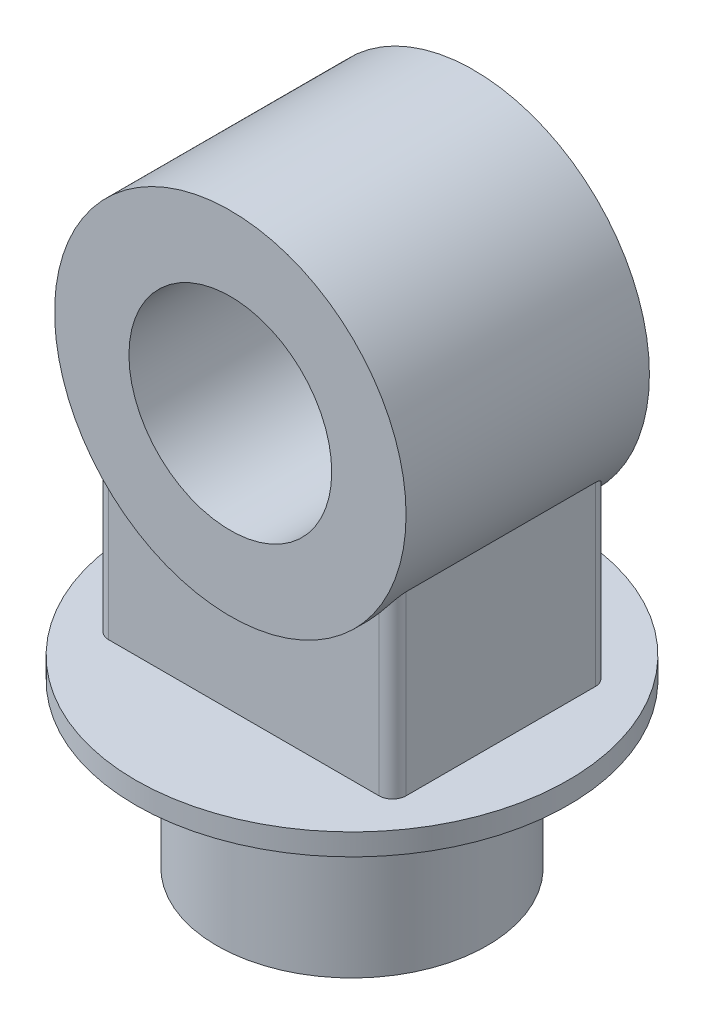
from build123d import *

# Parameters (mm, degrees)
SKETCH1_R           = 100
BOSS_EXTRUDE1_DEPTH = 120
SKETCH2_R           = 160
BOSS_EXTRUDE2_DEPTH = 16
SKETCH3_R           = 130
SKETCH3_R_2         = 75
BOSS_EXTRUDE3_DEPTH = 90
BOSS_EXTRUDE5_REACH = 402.125
SKETCH4_W           = 220
SKETCH4_H           = 160
FILLET1_R           = 10


with BuildPart() as part:
    # Sketch1 → Boss-Extrude1 (new body)
    with BuildSketch(Plane(origin=(0, 0, 0), x_dir=(1, 0, 0), z_dir=(0, 1, 0))):
        Circle(SKETCH1_R)
    extrude(amount=BOSS_EXTRUDE1_DEPTH)

    # Sketch2 → Boss-Extrude2 (add)
    with BuildSketch(Plane(origin=(0, 120, 0), x_dir=(1, 0, 0), z_dir=(0, 1, 0))):
        Circle(SKETCH2_R)
    extrude(amount=BOSS_EXTRUDE2_DEPTH)


with BuildPart() as body_2:
    # Sketch3 → Boss-Extrude3 (new, symmetric)
    with BuildSketch(Plane.XY):
        with Locations((0, 336)):
            Circle(SKETCH3_R)
        with Locations((0, 336)):
            Circle(SKETCH3_R_2, mode=Mode.SUBTRACT)
    extrude(amount=BOSS_EXTRUDE3_DEPTH, both=True)

    # Sketch4 → Boss-Extrude5 (add, up to next)
    with BuildSketch(Plane(origin=(0, 136, 0), x_dir=(1, 0, 0), z_dir=(0, 1, 0)), mode=Mode.PRIVATE) as boss_extrude5_sk1:
        Rectangle(SKETCH4_W, SKETCH4_H)
    boss_extrude5_tool1 = extrude(boss_extrude5_sk1.sketch, amount=BOSS_EXTRUDE5_REACH, mode=Mode.PRIVATE) - body_2.part

    add(part.part)  # Boss-Extrude5 merges part
    add(boss_extrude5_tool1.solids().sort_by_distance((0, 136, 0))[0])

    # Fillet1
    fillet1_edges = [body_2.edges().sort_by_distance(p)[0] for p in [
        (110, 201.358983849, -80),
        (110, 201.358983849, 80),
        (-110, 201.358983849, -80),
        (-110, 201.358983849, 80),
    ]]
    fillet(fillet1_edges, radius=FILLET1_R)


solid = body_2.part
